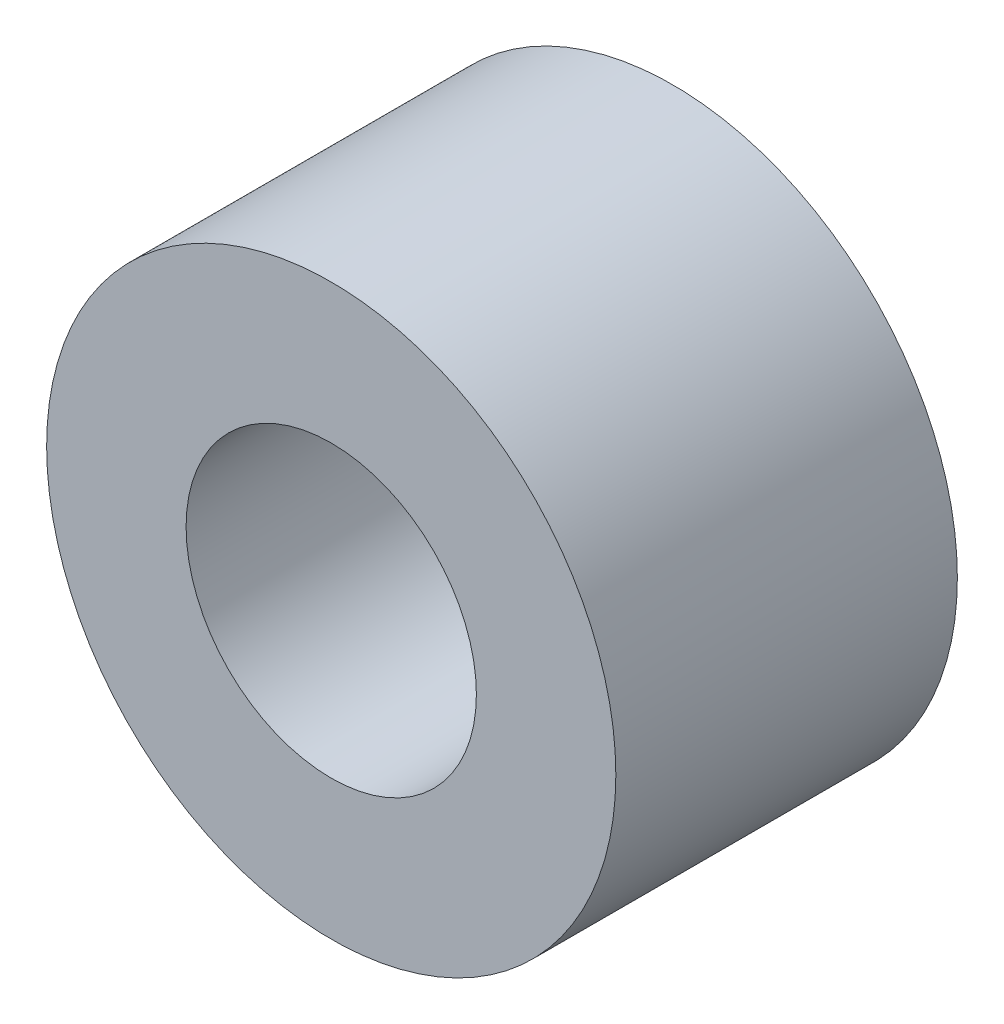
from build123d import *

# Parameters (mm, degrees)
SKETCH2_R           = 5
SKETCH2_R_2         = 2.55
BOSS_EXTRUDE1_DEPTH = 6


with BuildPart() as part:
    # Sketch2 → Boss-Extrude1 (new body)
    with BuildSketch(Plane.XY):
        Circle(SKETCH2_R)
        Circle(SKETCH2_R_2, mode=Mode.SUBTRACT)
    extrude(amount=BOSS_EXTRUDE1_DEPTH)


solid = part.part
